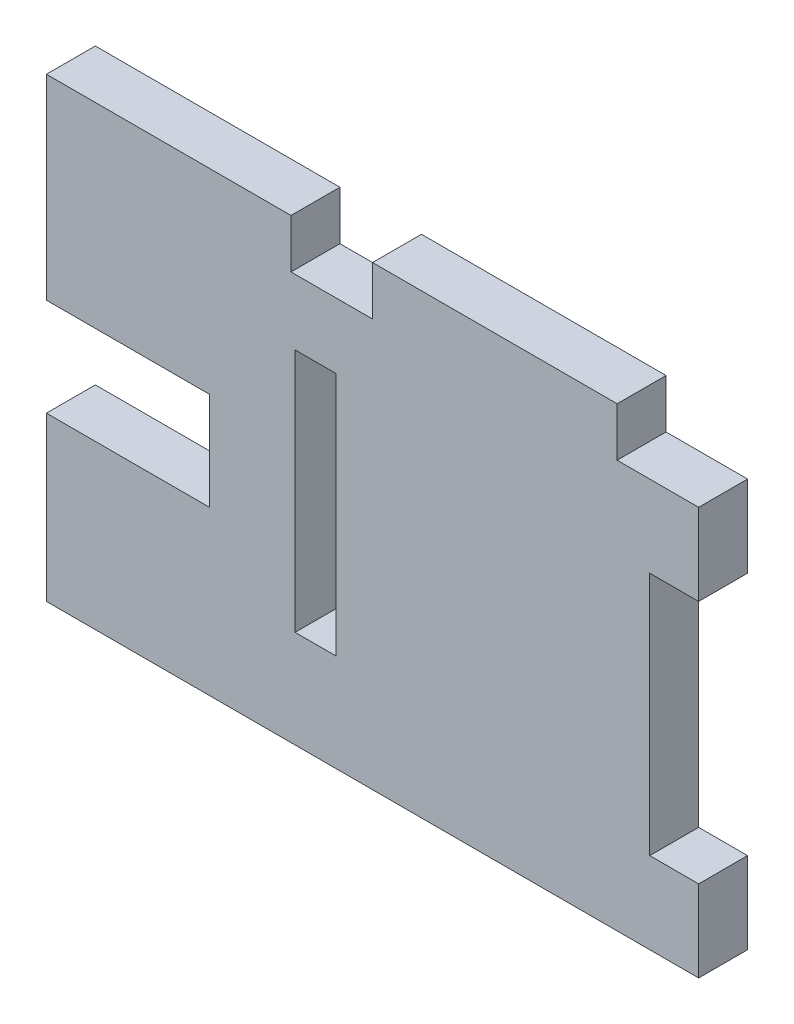
from build123d import *

# Parameters (mm, degrees)
SKETCH2_W           = 15
SKETCH2_H           = 6
SKETCH2_W_2         = 2.5
SKETCH2_H_2         = 15
BOSS_EXTRUDE1_DEPTH = 3
CUT_EXTRUDE1_DEPTH  = 4


with BuildPart() as part:
    # Sketch2 → Boss-Extrude1 (new body)
    with BuildSketch(Plane.XY):
        Polygon((-22.073806452, 10.862903226), (-22.073806452, 7.862903226), (-32.073806452, 7.862903226), (-32.073806452, -17.137096774), (17.926193548, -17.137096774), (17.926193548, -12.137096774), (14.926193548, -12.137096774), (14.926193548, 2.862903226), (17.926193548, 2.862903226), (17.926193548, 7.862903226), (12.926193548, 7.862903226), (12.926193548, 10.862903226), (-2.073806452, 10.862903226), (-2.073806452, 7.862903226), (-7.073806452, 7.862903226), (-7.073806452, 10.862903226), align=None)
        with Locations((-19.573806452, -4.137096774)):
            Rectangle(SKETCH2_W, SKETCH2_H, mode=Mode.SUBTRACT)
        with Locations((-5.573806452, -3.653225806)):
            Rectangle(SKETCH2_W_2, SKETCH2_H_2, mode=Mode.SUBTRACT)
    extrude(amount=BOSS_EXTRUDE1_DEPTH)

    # Sketch4 → Cut-Extrude1 (cut, through all)
    with BuildSketch(Plane.XY.offset(3)):
        Polygon((-22.073806452, 1.862903226), (-22.073806452, 7.862903226), (-32.073806452, 7.862903226), (-32.073806452, 1.862903226), (-32.073806452, -17.137096774), (-22.073806452, -17.137096774), align=None)
    extrude(amount=-CUT_EXTRUDE1_DEPTH, mode=Mode.SUBTRACT)


solid = part.part
